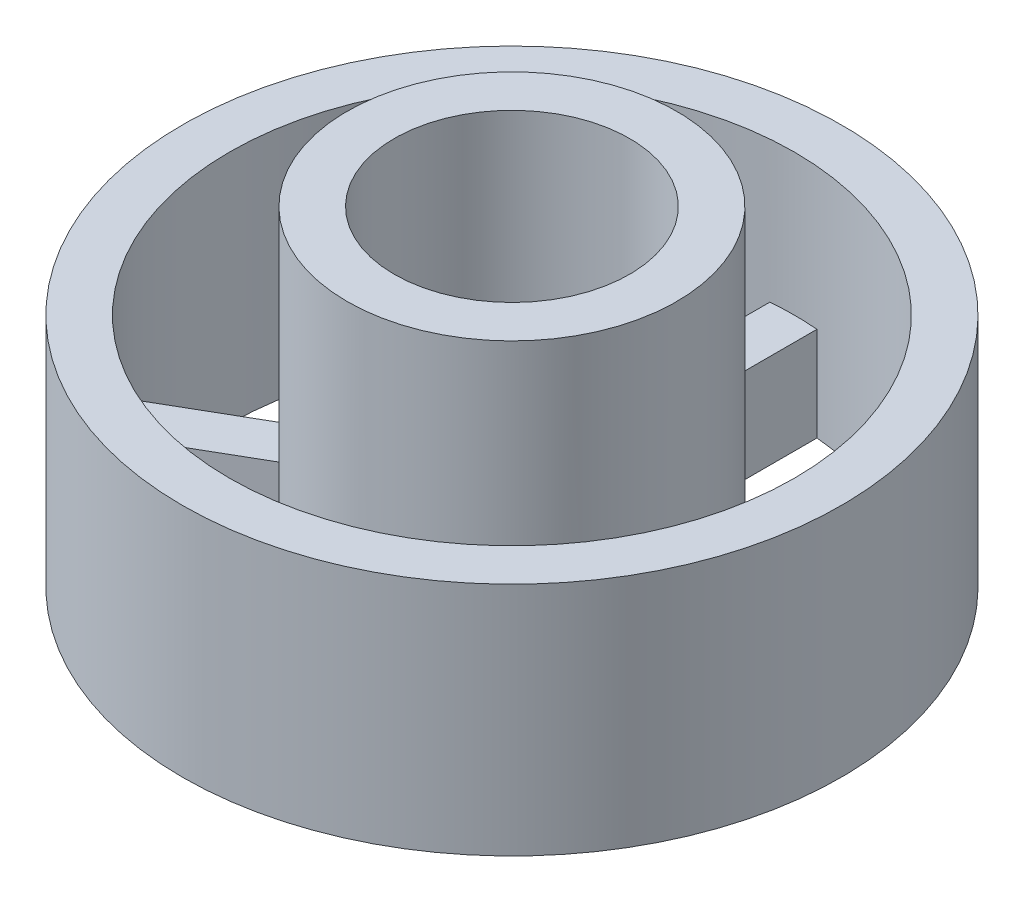
from build123d import *

# Parameters (mm, degrees)
SKETCH1_R           = 7
BOSS_EXTRUDE1_DEPTH = 5
SKETCH2_R           = 6
CUT_EXTRUDE1_DEPTH  = 3
SKETCH3_R           = 3.5
BOSS_EXTRUDE3_DEPTH = 5
SKETCH4_R           = 2.5
CUT_EXTRUDE2_DEPTH  = 8
CUT_EXTRUDE3_DEPTH  = 3


with BuildPart() as part:
    # Sketch1 → Boss-Extrude1 (new body)
    with BuildSketch(Plane(origin=(0, 0, 0), x_dir=(1, 0, 0), z_dir=(0, 1, 0))):
        Circle(SKETCH1_R)
    extrude(amount=BOSS_EXTRUDE1_DEPTH)

    # Sketch2 → Cut-Extrude1 (cut)
    with BuildSketch(Plane(origin=(0, 5, 0), x_dir=(1, 0, 0), z_dir=(0, 1, 0))):
        Circle(SKETCH2_R)
    extrude(amount=-CUT_EXTRUDE1_DEPTH, mode=Mode.SUBTRACT)

    # Sketch3 → Boss-Extrude3 (add)
    with BuildSketch(Plane(origin=(0, 2, 0), x_dir=(1, 0, 0), z_dir=(0, 1, 0))):
        Circle(SKETCH3_R)
    extrude(amount=BOSS_EXTRUDE3_DEPTH)

    # Sketch4 → Cut-Extrude2 (cut, through all)
    with BuildSketch(Plane(origin=(0, 7, 0), x_dir=(1, 0, 0), z_dir=(0, 1, 0))):
        Circle(SKETCH4_R)
    extrude(amount=-CUT_EXTRUDE2_DEPTH, mode=Mode.SUBTRACT)

    # Sketch5 → Cut-Extrude3 (cut, through all)
    with BuildSketch(Plane(origin=(0, 2, 0), x_dir=(1, 0, 0), z_dir=(0, 1, 0))):
        with BuildLine():
            Line((-0.5, 5.979130372), (-0.5, 3.464101615))
            ThreePointArc((-0.5, 3.464101615), (-3.031088913, 1.75), (-3.25, -1.299038106))
            Line((-3.25, -1.299038106), (-5.428078794, -2.556552484))
            ThreePointArc((-5.428078794, -2.556552484), (-5.196152423, 3), (-0.5, 5.979130372))
        make_face()
        with BuildLine():
            Line((0.5, 5.979130372), (0.5, 3.464101615))
            ThreePointArc((0.5, 3.464101615), (3.031088913, 1.75), (3.25, -1.299038106))
            Line((3.25, -1.299038106), (5.428078794, -2.556552484))
            ThreePointArc((5.428078794, -2.556552484), (5.196152423, 3), (0.5, 5.979130372))
        make_face()
        with BuildLine():
            Line((-4.928078794, -3.422577888), (-2.75, -2.165063509))
            ThreePointArc((-2.75, -2.165063509), (0, -3.5), (2.75, -2.165063509))
            Line((2.75, -2.165063509), (4.928078794, -3.422577888))
            ThreePointArc((4.928078794, -3.422577888), (0, -6), (-4.928078794, -3.422577888))
        make_face()
    extrude(amount=-CUT_EXTRUDE3_DEPTH, mode=Mode.SUBTRACT)


solid = part.part
